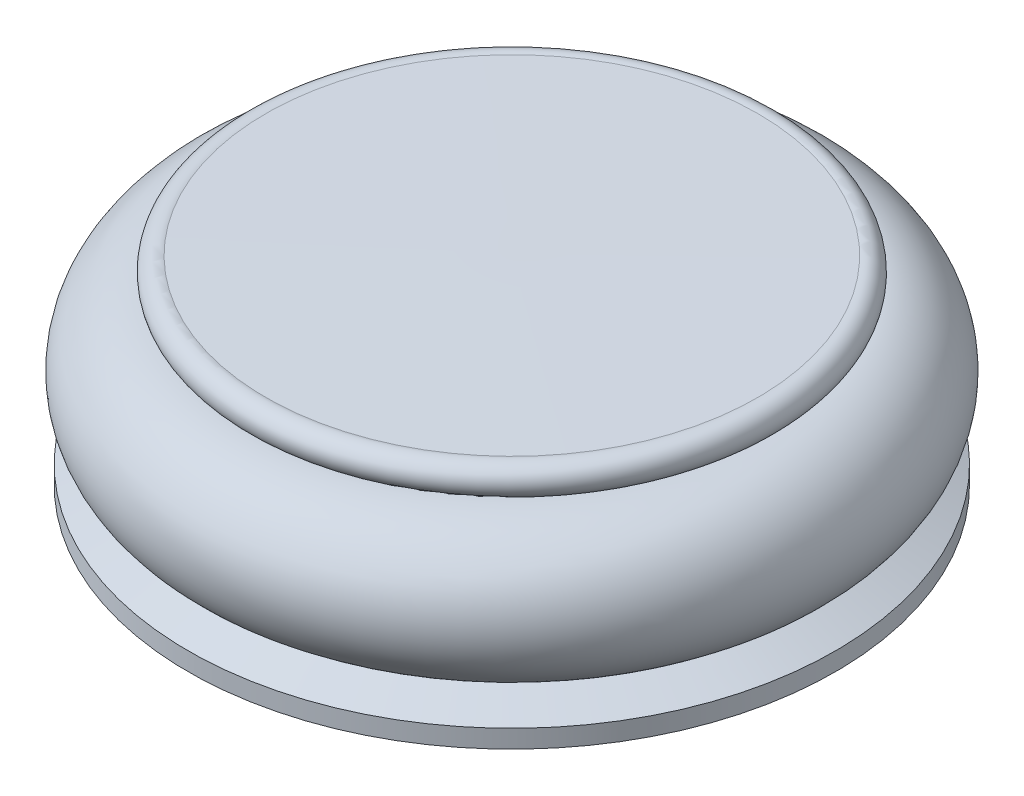
from build123d import *


with BuildPart() as part:
    # Sketch1 → Revolve1 (revolve)
    with BuildSketch(Plane.XY):
        with BuildLine():
            Line((0, 0), (0, -9.621899232))
            Line((0, -9.621899232), (15.56268383, -9.621899232))
            Line((15.56268383, -9.621899232), (15.56268383, -8.751500195))
            Line((15.56268383, -8.751500195), (13.893883706, -7.960560004))
            ThreePointArc((13.893883706, -7.960560004), (15.7471965, -4.023737944), (12.247020708, -1.438761027))
            Line((12.247020708, -1.438761027), (12.247020708, -1.432411027))
            ThreePointArc((12.247020708, -1.432411027), (12.705542595, -0.544113193), (11.827029404, -0.067112212))
            Line((11.827029404, -0.067112212), (0, 0))
        make_face()
    revolve(axis=Axis((0, -9.621899232, 0), (0, 1, 0)))


solid = part.part
